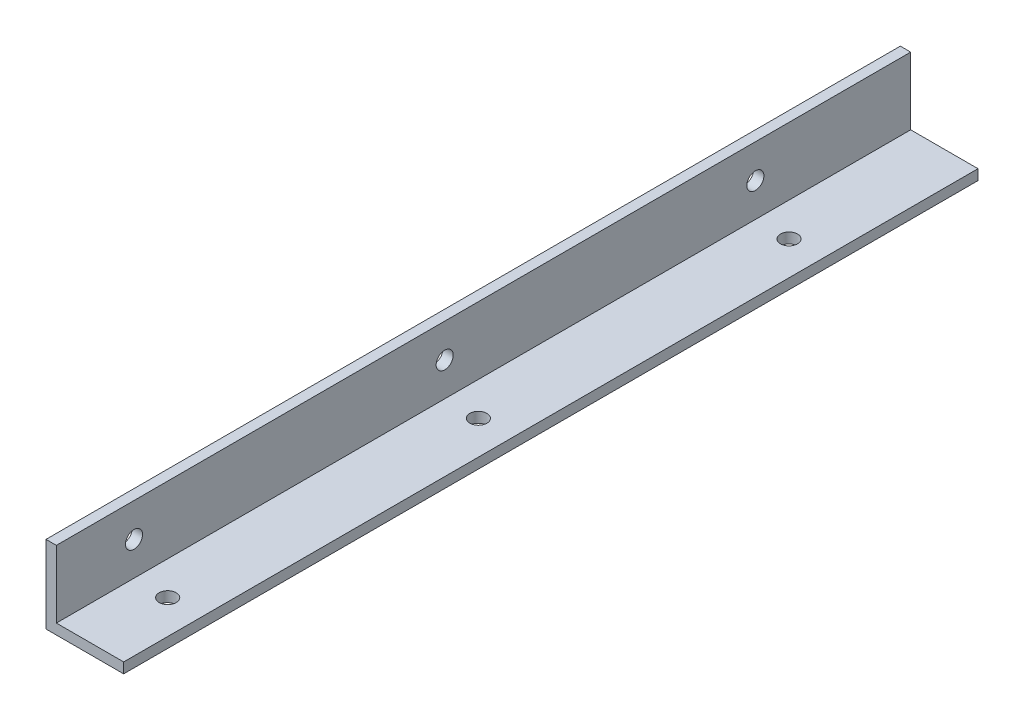
from build123d import *

# Parameters (mm, degrees)
EXTRUDE_1_DEPTH          = 150
EXTRUDE_2_DEPTH          = 15
M4X0_7_1_D               = 3.3
M4X0_7_1_DEPTH           = 11.5
M4X0_7_1_TIP             = 0.991420021
M4X0_7_1_ON_FACE_2_D     = 3.3
M4X0_7_1_ON_FACE_2_DEPTH = 11.5
M4X0_7_1_ON_FACE_2_TIP   = 0.991420021


with BuildPart() as part:
    # ｽｹｯﾁ1 → ﾎﾞｽ - 押し出し1 (new body)
    with BuildSketch(Plane.XY):
        Polygon((0, 0), (0, 15), (2, 15), (2, 2), (15, 2), (15, 0), align=None)
    extrude(amount=EXTRUDE_1_DEPTH)

    # ｽｹｯﾁ7 → ﾎﾞｽ - 押し出し2 (add)
    with BuildSketch(Plane(origin=(0, 0, 0), x_dir=(-1, 0, 0), z_dir=(0, 0, -1))):
        Polygon((-15, 2), (-2, 2), (-2, 15), (0, 15), (0, 0), (-15, 0), align=None)
    extrude(amount=EXTRUDE_2_DEPTH)

    # M4x0.7 ねじ穴1
    with Locations(Plane(origin=(8.5, 2, 15), x_dir=(0, 0, 1), z_dir=(0, 1, 0))):
        with Locations((0, 0), (60, 0), (120, 0)):
            Hole(M4X0_7_1_D / 2, depth=M4X0_7_1_DEPTH)
            with Locations((0, 0, -(M4X0_7_1_DEPTH + M4X0_7_1_TIP / 2))):  # 118° drill point
                Cone(0, M4X0_7_1_D / 2, M4X0_7_1_TIP, mode=Mode.SUBTRACT)

    # M4x0.7 ねじ穴1 on face 2
    with Locations(Plane(origin=(2, 8.5, 135), x_dir=(0, 0, 1), z_dir=(1, 0, 0))):
        with Locations((0, 0), (-60, 0), (-120, 0)):
            Hole(M4X0_7_1_ON_FACE_2_D / 2, depth=M4X0_7_1_ON_FACE_2_DEPTH)
            with Locations((0, 0, -(M4X0_7_1_ON_FACE_2_DEPTH + M4X0_7_1_ON_FACE_2_TIP / 2))):  # 118° drill point
                Cone(0, M4X0_7_1_ON_FACE_2_D / 2, M4X0_7_1_ON_FACE_2_TIP, mode=Mode.SUBTRACT)


solid = part.part
